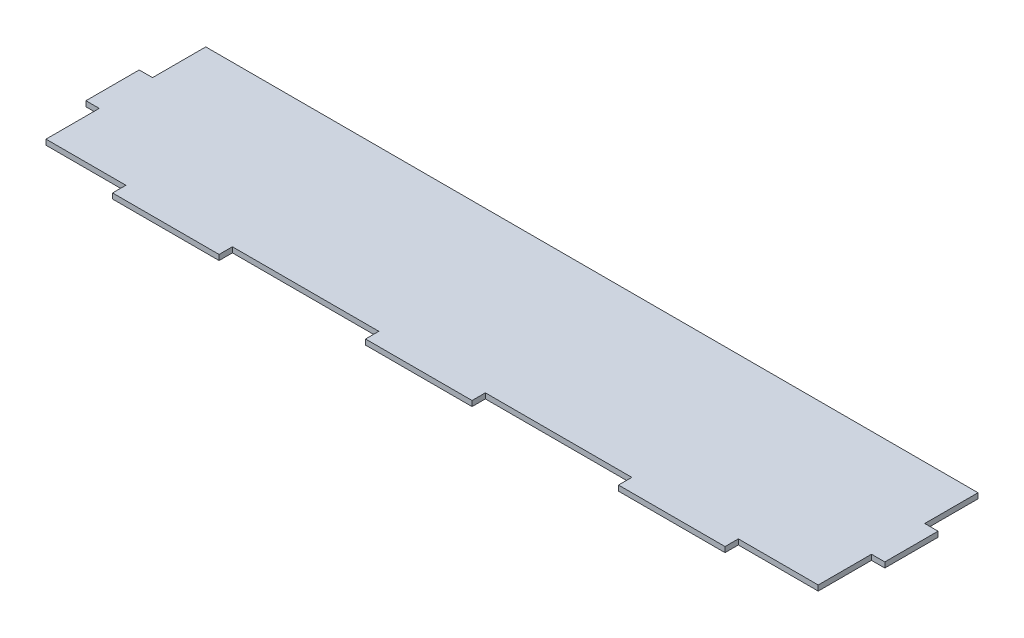
from build123d import *

# Parameters (mm, degrees)
BOSS_EXTRUDE1_DEPTH = 2.54


with BuildPart() as part:
    # Sketch1 → Boss-Extrude1 (new body)
    with BuildSketch(Plane(origin=(0, 0, 0), x_dir=(1, 0, 0), z_dir=(0, 1, 0))):
        Polygon((0, 12.434013317), (0, -12.965986683), (6.35, -12.965986683), (6.35, -38.365986683), (44.45, -38.365986683), (44.45, -44.715986683), (95.25, -44.715986683), (95.25, -38.365986683), (165.1, -38.365986683), (165.1, -44.715986683), (215.9, -44.715986683), (215.9, -38.365986683), (285.75, -38.365986683), (285.75, -44.715986683), (336.55, -44.715986683), (336.55, -38.365986683), (374.65, -38.365986683), (374.65, -12.965986683), (381, -12.965986683), (381, 12.434013317), (374.65, 12.434013317), (374.65, 37.834013317), (6.35, 37.834013317), (6.35, 12.434013317), align=None)
    extrude(amount=BOSS_EXTRUDE1_DEPTH)


solid = part.part
